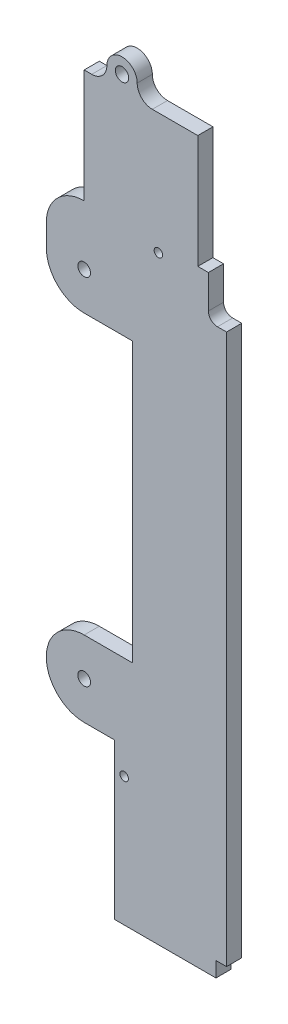
from build123d import *

# Parameters (mm, degrees)
SKETCH1_R           = 2.1
SKETCH1_R_2         = 2.2
BOSS_EXTRUDE1_DEPTH = 5
SKETCH2_R           = 1.4
CUT_EXTRUDE1_DEPTH  = 6


with BuildPart() as part:
    # Sketch1 → Boss-Extrude1 (new body)
    with BuildSketch(Plane.XY):
        with BuildLine():
            Line((41, 136.6), (41, 125.6))
            ThreePointArc((41, 125.6), (41.878679656, 123.478679656), (44, 122.6))
            Line((44, 122.6), (47, 122.6))
            Line((47, 122.6), (47, -29.8))
            Line((47, -29.8), (47, -58.8))
            Line((47, -58.8), (43.5, -58.8))
            Line((43.5, -58.8), (43.5, -63.8))
            Line((43.5, -63.8), (10, -63.8))
            Line((10, -63.8), (10, -29.8))
            Line((10, -29.8), (10, -12.5))
            Line((10, -12.5), (0, -12.5))
            ThreePointArc((0, -12.5), (-12.5, 0), (0, 12.5))
            Line((0, 12.5), (16, 12.5))
            Line((16, 12.5), (16, 104.5))
            Line((16, 104.5), (0, 104.5))
            ThreePointArc((0, 104.5), (-8.838834765, 108.161165235), (-12.5, 117))
            Line((-12.5, 117), (-12.5, 124.1))
            ThreePointArc((-12.5, 124.1), (-8.838834765, 132.938834765), (0, 136.6))
            Line((0, 136.6), (0, 174))
            Line((0, 174), (2.5, 174))
            ThreePointArc((2.5, 174), (6.035533906, 175.464466094), (7.5, 179))
            ThreePointArc((7.5, 179), (12.5, 184), (17.5, 179))
            ThreePointArc((17.5, 179), (18.964466094, 175.464466094), (22.5, 174))
            Line((22.5, 174), (37.5, 174))
            Line((37.5, 174), (37.5, 136.6))
            Line((37.5, 136.6), (41, 136.6))
        make_face()
        Circle(SKETCH1_R, mode=Mode.SUBTRACT)
        with Locations((0, 117)):
            Circle(SKETCH1_R, mode=Mode.SUBTRACT)
        with Locations((12.5, 179)):
            Circle(SKETCH1_R_2, mode=Mode.SUBTRACT)
    extrude(amount=BOSS_EXTRUDE1_DEPTH)

    # Sketch2 → Cut-Extrude1 (cut, through all)
    with BuildSketch(Plane.XY.offset(5)):
        with Locations((13.2, -21.3)):
            Circle(SKETCH2_R)
        with Locations((24.5, 134)):
            Circle(SKETCH2_R)
    extrude(amount=-CUT_EXTRUDE1_DEPTH, mode=Mode.SUBTRACT)


solid = part.part
